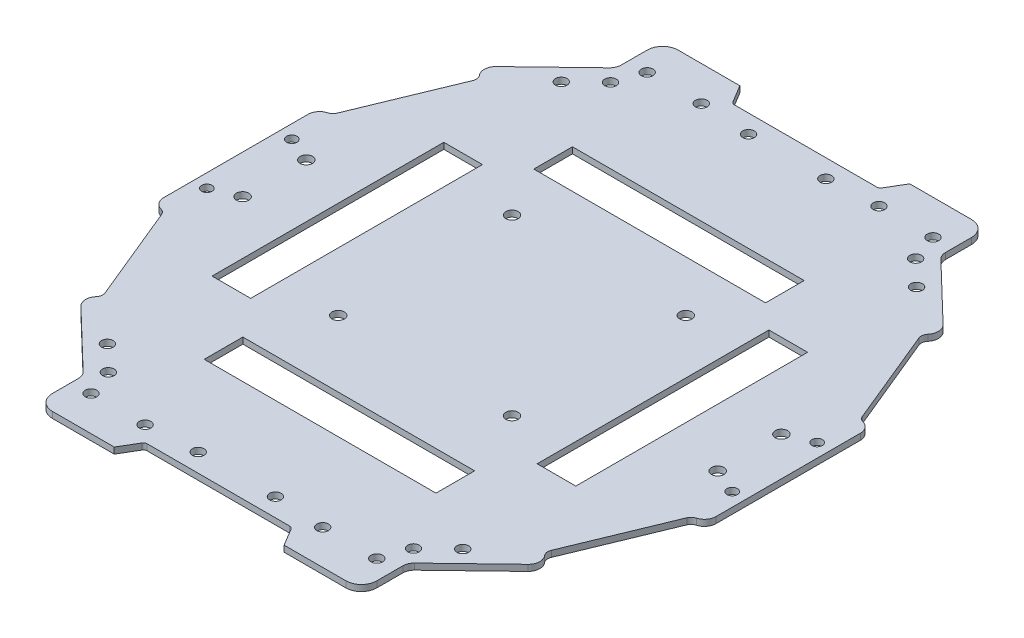
from build123d import *

# Parameters (mm, degrees)
SKETCH1_R          = 1.5
SKETCH1_R_2        = 1.600010398
SKETCH1_R_3        = 1.6
SKETCH1_R_4        = 1.35
EXTRUSION1_DEPTH   = 1.6
FILLET1_R          = 1
FILLET2_R          = 4
FILLET3_R          = 3
FILLET4_R          = 3
FILLET5_R          = 2
FILLET6_R          = 2
FILLET7_R          = 3
FILLET8_R          = 3
FILLET9_R          = 2
FILLET10_R         = 2
FILLET11_R         = 3
SKETCH2_W          = 60
SKETCH2_H          = 10
SKETCH2_W_2        = 10
SKETCH2_H_2        = 60
CUT_EXTRUDE1_DEPTH = 10


with BuildPart() as part:
    # Sketch1 → Extrusion1 (new body)
    with BuildSketch(Plane(origin=(0, 0, 0), x_dir=(-1, 0, 0), z_dir=(0, 1, 0))):
        Polygon((59.775158519, 259.059874387), (56.775158519, 264.05987395), (36.775158519, 264.05987395), (36.775158519, 252.05987395), (18.755330752, 234.731117294), (21.527931817, 231.847944851), (10.275158581, 204.559863083), (7.275158519, 204.559863083), (7.275158519, 183.059873956), (7.275158519, 161.559884829), (10.275158581, 161.559884829), (21.527931817, 134.27180306), (18.755330752, 131.388630617), (36.775158519, 114.059873961), (36.775158519, 102.059873961), (56.775158519, 102.059873961), (59.775158519, 107.059873524), (78.775158519, 107.059873524), (97.775158519, 107.059873524), (100.775158519, 102.059873961), (120.775158519, 102.059873961), (120.775158519, 114.059873961), (138.794986286, 131.388630617), (136.022385221, 134.27180306), (147.275158457, 161.559884829), (150.275158519, 161.559884829), (150.275158519, 183.059873956), (150.275158519, 204.559863083), (147.275158457, 204.559863083), (136.022385221, 231.847944851), (138.794986286, 234.731117294), (120.775158519, 252.05987395), (120.775158519, 264.05987395), (100.775158519, 264.05987395), (97.775158519, 259.059874387), (78.775158519, 259.059874387), align=None)
        with Locations((55.775158457, 111.059872631)):
            Circle(SKETCH1_R, mode=Mode.SUBTRACT)
        with Locations((39.275158457, 118.059884829)):
            Circle(SKETCH1_R, mode=Mode.SUBTRACT)
        with Locations((56.275158519, 205.559873956)):
            Circle(SKETCH1_R_2, mode=Mode.SUBTRACT)
        with Locations((17.275158457, 174.809872631)):
            Circle(SKETCH1_R_3, mode=Mode.SUBTRACT)
        with Locations((101.275158519, 205.559873956)):
            Circle(SKETCH1_R_2, mode=Mode.SUBTRACT)
        with Locations((56.275158519, 160.559873956)):
            Circle(SKETCH1_R_2, mode=Mode.SUBTRACT)
        with Locations((101.275158519, 160.559873956)):
            Circle(SKETCH1_R_2, mode=Mode.SUBTRACT)
        with Locations((41.775158457, 255.059863083)):
            Circle(SKETCH1_R, mode=Mode.SUBTRACT)
        with Locations((39.275158457, 248.059863083)):
            Circle(SKETCH1_R, mode=Mode.SUBTRACT)
        with Locations((10.775158457, 194.05987528)):
            Circle(SKETCH1_R_4, mode=Mode.SUBTRACT)
        with Locations((88.775158581, 111.809884829)):
            Circle(SKETCH1_R, mode=Mode.SUBTRACT)
        with Locations((115.775158581, 111.059884829)):
            Circle(SKETCH1_R, mode=Mode.SUBTRACT)
        with Locations((118.275158581, 118.059884829)):
            Circle(SKETCH1_R, mode=Mode.SUBTRACT)
        with Locations((140.275158581, 174.809872631)):
            Circle(SKETCH1_R_3, mode=Mode.SUBTRACT)
        with Locations((115.775158581, 255.059863083)):
            Circle(SKETCH1_R, mode=Mode.SUBTRACT)
        with Locations((88.775158581, 254.309863083)):
            Circle(SKETCH1_R, mode=Mode.SUBTRACT)
        with Locations((140.275158581, 191.30987528)):
            Circle(SKETCH1_R_3, mode=Mode.SUBTRACT)
        with Locations((146.775158581, 194.05987528)):
            Circle(SKETCH1_R_4, mode=Mode.SUBTRACT)
        with Locations((101.775158581, 255.05987528)):
            Circle(SKETCH1_R, mode=Mode.SUBTRACT)
        with Locations((118.275158581, 248.059863083)):
            Circle(SKETCH1_R, mode=Mode.SUBTRACT)
        with Locations((146.775158581, 172.059872631)):
            Circle(SKETCH1_R_4, mode=Mode.SUBTRACT)
        with Locations((101.775158581, 111.059872631)):
            Circle(SKETCH1_R, mode=Mode.SUBTRACT)
        with Locations((17.275158457, 191.30987528)):
            Circle(SKETCH1_R_3, mode=Mode.SUBTRACT)
        with Locations((55.775158457, 255.05987528)):
            Circle(SKETCH1_R, mode=Mode.SUBTRACT)
        with Locations((68.775158457, 254.309863083)):
            Circle(SKETCH1_R, mode=Mode.SUBTRACT)
        with Locations((10.775158457, 172.059872631)):
            Circle(SKETCH1_R_4, mode=Mode.SUBTRACT)
        with Locations((68.775158457, 111.809884829)):
            Circle(SKETCH1_R, mode=Mode.SUBTRACT)
        with Locations((41.775158457, 111.059884829)):
            Circle(SKETCH1_R, mode=Mode.SUBTRACT)
        with Locations((32.775158457, 124.309884829)):
            Circle(SKETCH1_R, mode=Mode.SUBTRACT)
        with Locations((124.775158581, 241.809863083)):
            Circle(SKETCH1_R, mode=Mode.SUBTRACT)
        with Locations((32.775158457, 241.809863083)):
            Circle(SKETCH1_R, mode=Mode.SUBTRACT)
        with Locations((124.775158581, 124.309884829)):
            Circle(SKETCH1_R, mode=Mode.SUBTRACT)
    extrude(amount=EXTRUSION1_DEPTH)

    # Fillet1
    fillet1_edges = [part.edges().sort_by_distance(p)[0] for p in [
        (-97.775158519, 0.8, 259.059874387),
        (-97.775158519, 0.8, 107.059873524),
        (-59.775158519, 0.8, 107.059873524),
        (-59.775158519, 0.8, 259.059874387),
    ]]
    fillet(fillet1_edges, radius=FILLET1_R)

    # Fillet2
    fillet2_edges = [part.edges().sort_by_distance(p)[0] for p in [
        (-120.775158519, 0.8, 264.05987395),
        (-120.775158519, 0.8, 102.059873961),
        (-36.775158519, 0.8, 102.059873961),
        (-36.775158519, 0.8, 264.05987395),
    ]]
    fillet(fillet2_edges, radius=FILLET2_R)

    # Fillet3
    fillet3_edges = [part.edges().sort_by_distance(p)[0] for p in [
        (-120.775158519, 0.8, 252.05987395),
        (-120.775158519, 0.8, 114.059873961),
        (-36.775158519, 0.8, 114.059873961),
        (-36.775158519, 0.8, 252.05987395),
    ]]
    fillet(fillet3_edges, radius=FILLET3_R)

    # Fillet4
    fillet4_edges = [part.edges().sort_by_distance(p)[0] for p in [
        (-138.794986286, 0.8, 234.731117294),
    ]]
    fillet(fillet4_edges, radius=FILLET4_R)

    # Fillet5
    fillet5_edges = [part.edges().sort_by_distance(p)[0] for p in [
        (-136.022385221, 0.8, 231.847944851),
    ]]
    fillet(fillet5_edges, radius=FILLET5_R)

    # Fillet6
    fillet6_edges = [part.edges().sort_by_distance(p)[0] for p in [
        (-21.527931817, 0.8, 231.847944851),
    ]]
    fillet(fillet6_edges, radius=FILLET6_R)

    # Fillet7
    fillet7_edges = [part.edges().sort_by_distance(p)[0] for p in [
        (-18.755330752, 0.8, 234.731117294),
    ]]
    fillet(fillet7_edges, radius=FILLET7_R)

    # Fillet8
    fillet8_edges = [part.edges().sort_by_distance(p)[0] for p in [
        (-138.794986286, 0.8, 131.388630617),
        (-18.755330752, 0.8, 131.388630617),
    ]]
    fillet(fillet8_edges, radius=FILLET8_R)

    # Fillet9
    fillet9_edges = [part.edges().sort_by_distance(p)[0] for p in [
        (-21.527931817, 0.8, 134.27180306),
        (-136.022385221, 0.8, 134.27180306),
    ]]
    fillet(fillet9_edges, radius=FILLET9_R)

    # Fillet10
    fillet10_edges = [part.edges().sort_by_distance(p)[0] for p in [
        (-147.275158457, 0.8, 204.559863083),
        (-147.275158457, 0.8, 161.559884829),
        (-10.275158581, 0.8, 161.559884829),
        (-10.275158581, 0.8, 204.559863083),
    ]]
    fillet(fillet10_edges, radius=FILLET10_R)

    # Fillet11
    fillet11_edges = [part.edges().sort_by_distance(p)[0] for p in [
        (-150.275158519, 0.8, 161.559884829),
        (-150.275158519, 0.8, 204.559863083),
        (-7.275158519, 0.8, 204.559863083),
        (-7.275158519, 0.8, 161.559884829),
    ]]
    fillet(fillet11_edges, radius=FILLET11_R)

    # Sketch2 → Cut-Extrude1 (cut)
    with BuildSketch(Plane(origin=(0, 1.6, 0), x_dir=(1, 0, 0), z_dir=(0, 1, 0))):
        with Locations((-78.775158519, -227.740052345)):
            Rectangle(SKETCH2_W, SKETCH2_H)
        with Locations((-121.427823397, -183.059873956)):
            Rectangle(SKETCH2_W_2, SKETCH2_H_2)
        with Locations((-37.255421575, -183.059873956)):
            Rectangle(SKETCH2_W_2, SKETCH2_H_2)
        with Locations((-78.775158519, -142.417413153)):
            Rectangle(SKETCH2_W, SKETCH2_H)
    extrude(amount=-CUT_EXTRUDE1_DEPTH, mode=Mode.SUBTRACT)


solid = part.part
